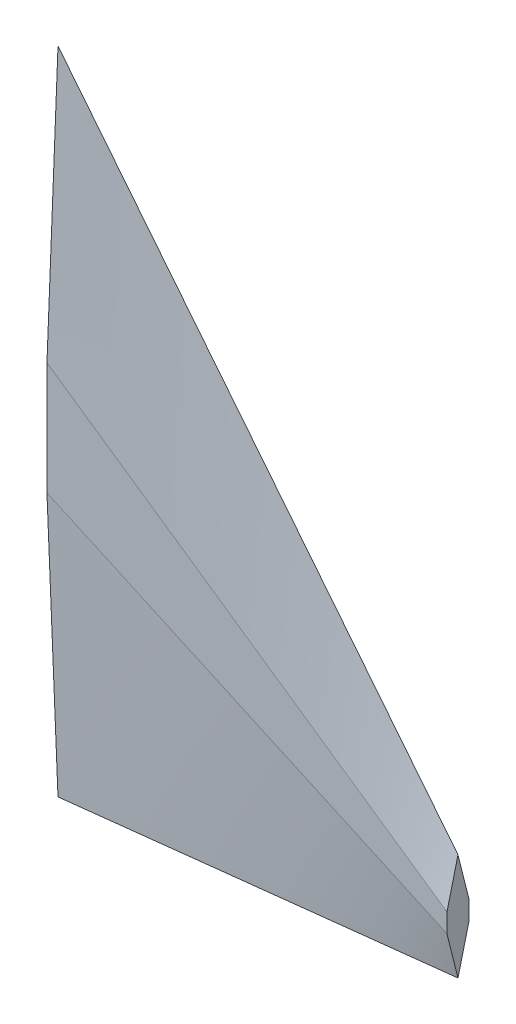
from build123d import *


with BuildPart() as part:
    # Sketch1 → Loft1 section 0
    with BuildSketch(Plane(origin=(0, 0, 0), x_dir=(0, 0, -1), z_dir=(1, 0, 0))):
        Polygon((0, 74.29), (2.521153846, 12.87), (2.521153846, -12.87), (0, -74.29), (-2.521153846, -12.87), (-2.521153846, 12.87), align=None)
    # Sketch2 → Loft1 section 1
    with BuildSketch(Plane(origin=(91.39, 0, 0), x_dir=(0, 0, -1), z_dir=(1, 0, 0))):
        Polygon((0, -64.424), (2.521153846, -54.391), (2.521153846, -50.073), (0, -40.04), (-2.521153846, -50.073), (-2.521153846, -54.391), align=None)
    loft()


solid = part.part
